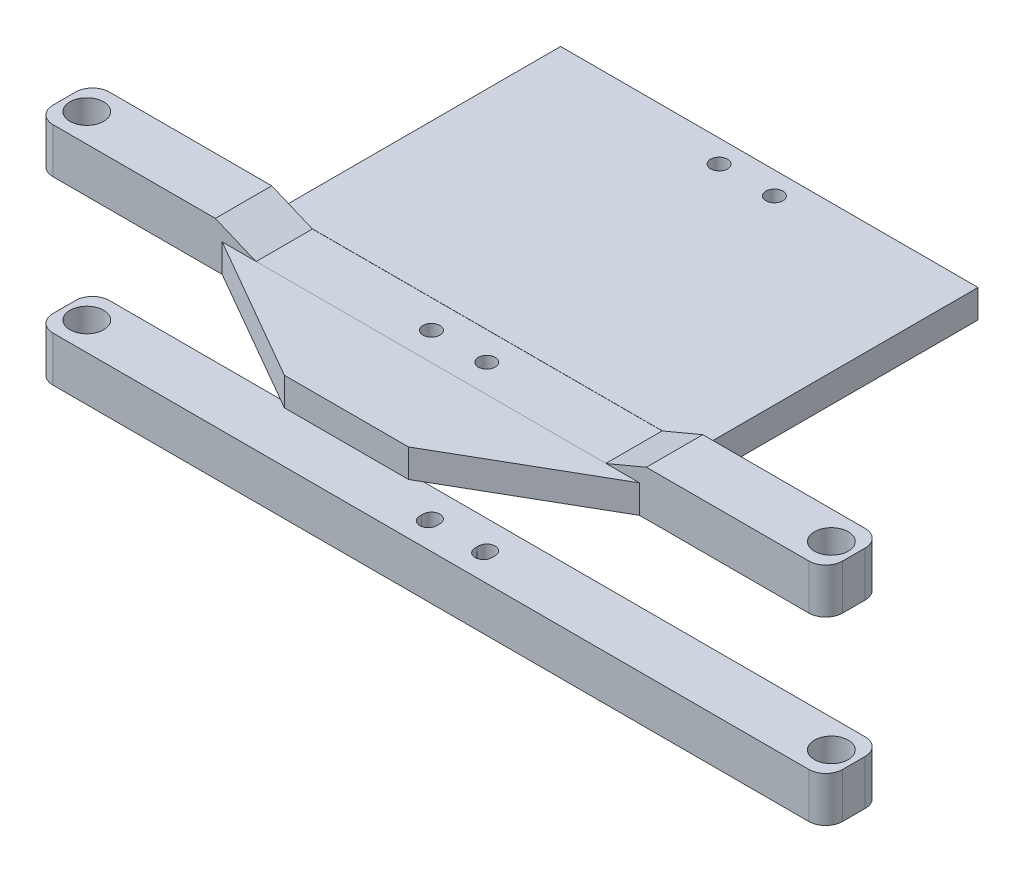
from build123d import *

# Parameters (mm, degrees)
SKETCH1_R               = 1.5
BOSS_EXTRUDE1_DEPTH     = 40
SKETCH3_W               = 10
SKETCH3_H               = 24
CUT_EXTRUDE1_DEPTH      = 71
CUT_EXTRUDE1_DEPTH_BACK = 71
FILLET2_R               = 3
FILLET3_R               = 3
BOSS_EXTRUDE4_START     = 32
SKETCH7_R               = 1.5
BOSS_EXTRUDE4_DEPTH     = 5
BOSS_EXTRUDE5_START     = 10
SKETCH7_5_W             = 20
SKETCH7_5_H             = 7.5
SKETCH7_5_R             = 1.5
BOSS_EXTRUDE5_DEPTH     = 22
SKETCH5_R               = 1.5
CUT_EXTRUDE4_DEPTH      = 11
SKETCH4_R               = 3
CUT_EXTRUDE2_DEPTH      = 41
CUT_EXTRUDE2_DEPTH_BACK = 1
CUT_EXTRUDE6_DEPTH      = 10


with BuildPart() as part:
    # Sketch1 → Boss-Extrude1 (new body)
    with BuildSketch(Plane(origin=(0, 0, 0), x_dir=(1, 0, 0), z_dir=(0, 1, 0))):
        Polygon((-70, 10), (-15, 10), (-11, 10), (11, 10), (15, 10), (70, 10), (70, 0), (-70, 0), align=None)
        with Locations((-4.9, 5)):
            Circle(SKETCH1_R, mode=Mode.SUBTRACT)
        with Locations((4.9, 5)):
            Circle(SKETCH1_R, mode=Mode.SUBTRACT)
    extrude(amount=BOSS_EXTRUDE1_DEPTH)

    # Sketch3 → Cut-Extrude1 (cut, two sides)
    with BuildSketch(Plane(origin=(0, 0, 0), x_dir=(0, 0, -1), z_dir=(1, 0, 0))) as cut_extrude1_sk:
        with Locations((5, 20)):
            Rectangle(SKETCH3_W, SKETCH3_H)
    extrude(amount=CUT_EXTRUDE1_DEPTH, mode=Mode.SUBTRACT)
    extrude(cut_extrude1_sk.sketch, amount=-CUT_EXTRUDE1_DEPTH_BACK, mode=Mode.SUBTRACT)

    # Fillet2
    fillet2_edges = [part.edges().sort_by_distance(p)[0] for p in [
        (70, 36, -10),
        (-70, 36, -10),
        (-70, 36, 0),
        (70, 36, 0),
    ]]
    fillet(fillet2_edges, radius=FILLET2_R)

    # Fillet3
    fillet3_edges = [part.edges().sort_by_distance(p)[0] for p in [
        (70, 4, -10),
        (70, 4, 0),
        (-70, 4, 0),
        (-70, 4, -10),
    ]]
    fillet(fillet3_edges, radius=FILLET3_R)

    # Sketch5 → Cut-Extrude4 (cut, symmetric)
    with BuildSketch(Plane(origin=(0, 0, 0), x_dir=(1, 0, 0), z_dir=(0, 1, 0))):
        with Locations((-4.9, 4.44843495)):
            Circle(SKETCH5_R)
        with Locations((4.9, 4.44843495)):
            Circle(SKETCH5_R)
    extrude(amount=CUT_EXTRUDE4_DEPTH, both=True, mode=Mode.SUBTRACT)

    # Sketch4 → Cut-Extrude2 (cut, two sides)
    with BuildSketch(Plane(origin=(0, 0, 0), x_dir=(1, 0, 0), z_dir=(0, 1, 0))) as cut_extrude2_sk:
        with Locations((-66, 5)):
            Circle(SKETCH4_R)
        with Locations((66, 5)):
            Circle(SKETCH4_R)
    extrude(amount=CUT_EXTRUDE2_DEPTH, mode=Mode.SUBTRACT)
    extrude(cut_extrude2_sk.sketch, amount=-CUT_EXTRUDE2_DEPTH_BACK, mode=Mode.SUBTRACT)


with BuildPart() as body_2:
    # Sketch7 → Boss-Extrude4 (new body)
    with BuildSketch(Plane(origin=(0, 0, 0), x_dir=(1, 0, 0), z_dir=(0, 1, 0)).offset(BOSS_EXTRUDE4_START)):
        Polygon((-37, 0), (-11, -14.966629547), (11, -14.966629547), (37, 0), (37, 60), (-37, 60), align=None)
        with Locations((-4.9, 56)):
            Circle(SKETCH7_R, mode=Mode.SUBTRACT)
        with Locations((4.9, 56)):
            Circle(SKETCH7_R, mode=Mode.SUBTRACT)
        with Locations((-4.9, 5)):
            Circle(SKETCH7_R, mode=Mode.SUBTRACT)
        with Locations((4.9, 5)):
            Circle(SKETCH7_R, mode=Mode.SUBTRACT)
    extrude(amount=BOSS_EXTRUDE4_DEPTH)

    # Sketch7_5 → Boss-Extrude5 (add)
    with BuildSketch(Plane(origin=(0, 0, 0), x_dir=(1, 0, 0), z_dir=(0, 1, 0)).offset(BOSS_EXTRUDE5_START)):
        with Locations((0, 56.25)):
            Rectangle(SKETCH7_5_W, SKETCH7_5_H)
        with Locations((4.9, 56)):
            Circle(SKETCH7_5_R, mode=Mode.SUBTRACT)
        with Locations((-4.9, 56)):
            Circle(SKETCH7_5_R, mode=Mode.SUBTRACT)
    extrude(amount=BOSS_EXTRUDE5_DEPTH)


with BuildPart() as cut_extrude6_tool:
    # Sketch9 → Cut-Extrude6 (new body)
    with BuildSketch(Plane.XY):
        Polygon((-38.210891508, 40), (-31, 36.971825845), (31, 36.971825845), (38.210891508, 40), align=None)
    extrude(amount=-CUT_EXTRUDE6_DEPTH)


with BuildPart() as part_1:
    add(part.part)

    # Cut-Extrude6: cut by cut_extrude6_tool
    add(cut_extrude6_tool.part, mode=Mode.SUBTRACT)


with BuildPart() as body_2_1:
    add(body_2.part)

    # Cut-Extrude6: cut by cut_extrude6_tool
    add(cut_extrude6_tool.part, mode=Mode.SUBTRACT)


solid = Compound([part_1.part, body_2_1.part])
